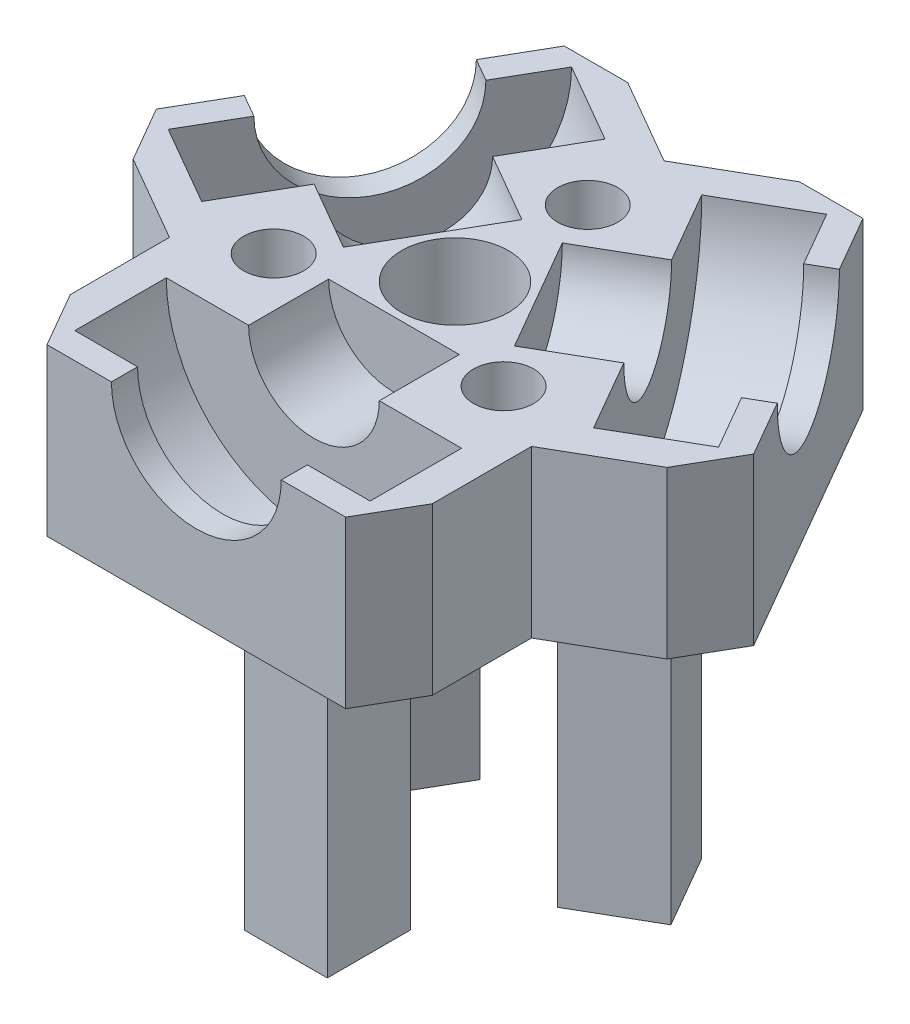
from build123d import *

# Parameters (mm, degrees)
BOSS_EXTRUDE1_DEPTH = 12.7
SKETCH2_R           = 7.100000009
SKETCH2_R_2         = 4.100000009
BOSS_EXTRUDE2_DEPTH = 3.499999906
SKETCH4_W           = 6.35
SKETCH4_H           = 6.35
BOSS_EXTRUDE4_DEPTH = 25.4
CIRPATTERN1_COUNT   = 3
SKETCH6_R           = 4.100000009
CUT_EXTRUDE1_DEPTH  = 39.1
SKETCH7_R           = 2.3
CUT_EXTRUDE2_DEPTH  = 5.7
CUT_EXTRUDE4_DEPTH  = 39.1


with BuildPart() as part:
    # Sketch1 → Boss-Extrude1 (new body)
    with BuildSketch(Plane(origin=(0, 0, 0), x_dir=(1, 0, 0), z_dir=(0, 1, 0))):
        Polygon((11.43, -19.797340731), (22.86, 0), (11.43, 19.797340731), (-11.43, 19.797340731), (-22.86, 0), (-11.43, -19.797340731), align=None)
    extrude(amount=BOSS_EXTRUDE1_DEPTH)

    # Sketch2 → Boss-Extrude2 (add)
    with BuildSketch(Plane.XZ):
        Circle(SKETCH2_R)
        Circle(SKETCH2_R_2, mode=Mode.SUBTRACT)
    extrude(amount=BOSS_EXTRUDE2_DEPTH)

    # Sketch4 → Boss-Extrude4 (add)
    with BuildSketch(Plane.XZ):
        Polygon((12.802528987, -3.725369347), (7.303267673, -0.550369347), (4.128267673, -6.049630662), (9.627528987, -9.224630662), align=None)
        with Locations((0, 9.775000009)):
            Rectangle(SKETCH4_W, SKETCH4_H)
        Polygon((-9.627528987, -9.224630662), (-4.128267673, -6.049630662), (-7.303267673, -0.550369347), (-12.802528987, -3.725369347), align=None)
    extrude(amount=BOSS_EXTRUDE4_DEPTH)

    # Sketch5 → Cut-Revolve1 (revolve, cut)
    with BuildSketch(Plane(origin=(0, 12.7, 0), x_dir=(1, 0, 0), z_dir=(0, 1, 0))):
        Polygon((0, -19.797340731), (0, -4.672340739), (-5, -4.672340739), (-5, -10.797340731), (-11.300000152, -10.797340731), (-11.300000152, -17.797340731), (-6.5, -17.797340731), (-6.5, -19.797340731), align=None)
    cut_revolve1 = revolve(axis=Axis((0, 12.7, 19.797340731), (0, 0, -1)), mode=Mode.SUBTRACT)

    # CirPattern1: Cut-Revolve1 ×3 about axis
    cirpattern1_axis = Axis((0, 0, 0), (0, 1, 0))
    for i in range(1, CIRPATTERN1_COUNT):
        add(cut_revolve1.rotate(cirpattern1_axis, i * 360 / CIRPATTERN1_COUNT), mode=Mode.SUBTRACT)

    # Sketch6 → Cut-Extrude1 (cut, through all)
    with BuildSketch(Plane(origin=(0, 12.7, 0), x_dir=(1, 0, 0), z_dir=(0, 1, 0))):
        Circle(SKETCH6_R)
    extrude(amount=-CUT_EXTRUDE1_DEPTH, mode=Mode.SUBTRACT)

    # Sketch7 → Cut-Extrude2 (cut)
    with BuildSketch(Plane(origin=(0, 12.7, 0), x_dir=(1, 0, 0), z_dir=(0, 1, 0))):
        with Locations((0, 10.16)):
            Circle(SKETCH7_R)
        with Locations((8.798818102, -5.08)):
            Circle(SKETCH7_R)
        with Locations((-8.798818102, -5.08)):
            Circle(SKETCH7_R)
    extrude(amount=-CUT_EXTRUDE2_DEPTH, mode=Mode.SUBTRACT)

    # Sketch9 → Cut-Extrude4 (cut, through all)
    with BuildSketch(Plane(origin=(0, 12.7, 0), x_dir=(1, 0, 0), z_dir=(0, 1, 0))):
        Polygon((-6.577186816, 19.797340731), (0, 16.000000152), (6.577186816, 19.797340731), align=None)
        Polygon((20.433593408, -4.202659497), (13.856406592, -8.000000076), (13.856406592, -15.594681234), align=None)
        Polygon((-13.856406592, -15.594681234), (-13.856406592, -8.000000076), (-20.433593408, -4.202659497), align=None)
    extrude(amount=-CUT_EXTRUDE4_DEPTH, mode=Mode.SUBTRACT)


solid = part.part
